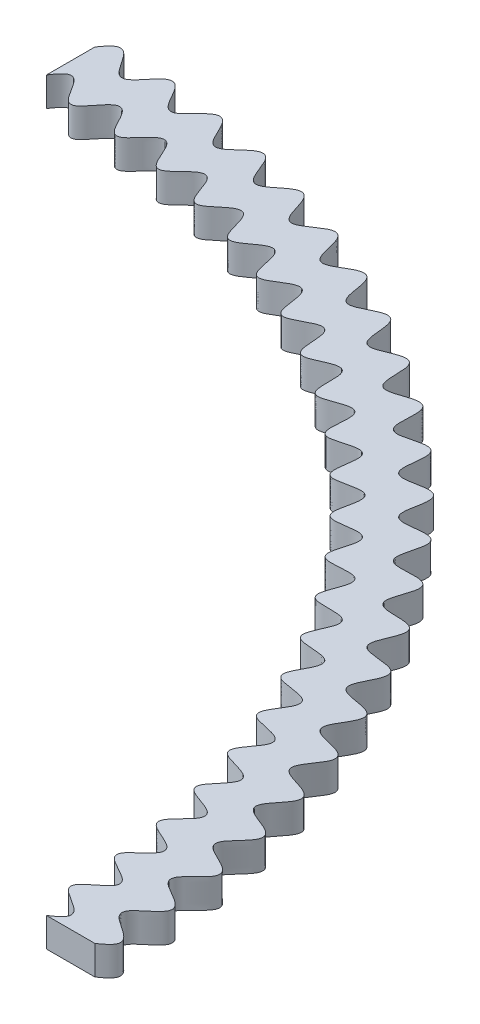
from build123d import *

# Parameters (mm, degrees)
BOSS_EXTRUDE1_DEPTH = 3


with BuildPart() as part:
    # Sketch1 → Boss-Extrude1 (new body)
    with BuildSketch(Plane(origin=(0, 0, 0), x_dir=(1, 0, 0), z_dir=(0, 1, 0))):
        with BuildLine():
            Line((0, 74.999999999), (-3e-09, 79.999999995))
            add(Edge.make_bspline(
                [(80.000000006, 4e-09), (80.041602981, 0.029584342), (80.124672241, 0.088800082), (80.355665628, 0.255037075), (80.580689501, 0.428196266), (80.81426022, 0.628581279), (81.018283424, 0.851310159), (81.156118976, 1.051783354), (81.240847835, 1.272600388), (81.246016618, 1.500136483), (81.179439662, 1.70644663), (81.072093968, 1.882262489), (80.890390621, 2.096864584), (80.621041123, 2.332166671), (80.269616744, 2.584320872), (79.896985228, 2.827334114), (79.578764212, 3.037245118), (79.320425694, 3.220223576), (79.121721975, 3.374962874), (78.935873528, 3.54358104), (78.77263698, 3.733120429), (78.655258735, 3.95143766), (78.623837205, 4.193153253), (78.683771629, 4.421996142), (78.795973835, 4.620716323), (78.984584597, 4.861193351), (79.260256835, 5.129313501), (79.61405676, 5.426162183), (80.034933674, 5.765657885), (80.383334361, 6.069053516), (80.64916782, 6.347378113), (80.823997803, 6.598345889), (80.921414722, 6.805042914), (80.956081188, 7.00900363), (80.930346952, 7.189278292), (80.85921354, 7.366686331), (80.745433267, 7.533712712), (80.581106502, 7.70084266), (80.324453782, 7.904792803), (79.998299993, 8.115192146), (79.608972329, 8.337012133), (79.219952014, 8.552844577), (78.892674075, 8.748998283), (78.64592559, 8.921468474), (78.475904636, 9.061875815), (78.334858695, 9.209053996), (78.228156569, 9.363513244), (78.155173955, 9.554557891), (78.149754157, 9.776640258), (78.224125673, 10.002339681), (78.352006264, 10.217315502), (78.505739272, 10.415655274), (78.67455645, 10.602546042), (78.897195963, 10.827604877), (79.174131922, 11.089585334), (79.498903574, 11.393613444), (79.801202697, 11.702961078), (80.025600848, 11.981460378), (80.167277188, 12.224354966), (80.242468592, 12.41613789), (80.271819825, 12.628249297), (80.229522967, 12.84617985), (80.114958572, 13.043632683), (79.954763592, 13.212416248), (79.720296679, 13.397936958), (79.407072249, 13.587360322), (79.021163384, 13.781984947), (78.56862328, 13.992615128), (78.180049517, 14.181676146), (77.861870547, 14.362378528), (77.620410564, 14.538567295), (77.452426806, 14.699555409), (77.32417893, 14.896997355), (77.274027447, 15.128431228), (77.311347084, 15.361169155), (77.402874819, 15.575335259), (77.557886293, 15.830947416), (77.783602416, 16.118944371), (78.072308857, 16.440385913), (78.413020367, 16.805019864), (78.698748435, 17.129144266), (78.919925667, 17.420606018), (79.070830754, 17.678529716), (79.160125788, 17.893107893), (79.199493523, 18.11766681), (79.166110244, 18.337116848), (79.066113723, 18.526654792), (78.928041208, 18.67989037), (78.758095077, 18.815824302), (78.563403255, 18.937780229), (78.292286184, 19.078874506), (77.94208218, 19.230391033), (77.586564337, 19.368174358), (77.231347046, 19.506941759), (76.940204295, 19.631303183), (76.71304398, 19.740085414), (76.495059028, 19.864369098), (76.293843648, 20.012665137), (76.133111289, 20.19192684), (76.044903019, 20.403806455), (76.03759153, 20.619301189), (76.082831413, 20.816111271), (76.166851605, 21.018822907), (76.283150766, 21.226158295), (76.464160707, 21.496087875), (76.715848987, 21.822467796), (77.019348781, 22.195304011), (77.30833389, 22.569732882), (77.525684967, 22.90276604), (77.662974457, 23.192900926), (77.732396671, 23.428451641), (77.738105048, 23.673858143), (77.65403286, 23.901813951), (77.501220493, 24.084150899), (77.316617595, 24.22536767), (77.056961821, 24.373272726), (76.719688353, 24.515101473), (76.310177077, 24.652935319), (75.83279604, 24.798363036), (75.422047724, 24.932385671), (75.082573559, 25.06894062), (74.82052353, 25.212801385), (74.634175154, 25.352510833), (74.485486432, 25.535407965), (74.413201955, 25.760911321), (74.4255469, 25.996025), (74.490531045, 26.219436675), (74.611547141, 26.492750615), (74.79674702, 26.808332953), (75.038731262, 27.16635148), (75.325327397, 27.575032619), (75.562221965, 27.936536922), (75.738770596, 28.257194582), (75.849064544, 28.535093686), (75.903405684, 28.761362031), (75.903894944, 28.989643398), (75.831559821, 29.199525222), (75.700085204, 29.368543472), (75.539076074, 29.497036653), (75.294933478, 29.636551374), (74.961349304, 29.765539744), (74.544876825, 29.882293142), (74.111602173, 29.983203304), (73.74077851, 30.071617178), (73.435437364, 30.155203688), (73.195792998, 30.232650396), (72.963481772, 30.327535729), (72.745263303, 30.449814307), (72.560294942, 30.614819673), (72.448096761, 30.831211236), (72.426147819, 31.06675199), (72.4636171, 31.291863293), (72.558605253, 31.582346461), (72.725949928, 31.928582446), (72.956884879, 32.328535664), (73.236265441, 32.791505652), (73.459887578, 33.19576434), (73.614496699, 33.548224307), (73.692947109, 33.843852251), (73.713794523, 34.071402468), (73.676611673, 34.274919478), (73.590771834, 34.435520621), (73.46325117, 34.577900586), (73.2992063, 34.695938898), (73.087627842, 34.796786613), (72.776698118, 34.900656658), (72.398252997, 34.986816202), (71.956537759, 35.062100903), (71.517159196, 35.131864274), (71.142530013, 35.204252817), (70.851674004, 35.28192883), (70.643884429, 35.355717981), (70.461006697, 35.44577968), (70.307911322, 35.554429618), (70.17398898, 35.708991339), (70.092939393, 35.915826821), (70.085632009, 36.153351459), (70.132274396, 36.399100391), (70.208899972, 36.638058596), (70.303615821, 36.871417347), (70.435853873, 37.159050671), (70.606485957, 37.499949451), (70.807687744, 37.896720868), (70.985952877, 38.290804947), (71.101565793, 38.629257372), (71.151623163, 38.905959786), (71.156686347, 39.11189376), (71.11172111, 39.321251997), (70.997438426, 39.511573351), (70.822250264, 39.65793499), (70.613988844, 39.761749751), (70.330210196, 39.855889786), (69.971088905, 39.926760459), (69.541887649, 39.977659178), (69.044599288, 40.020808973), (68.614796714, 40.065568163), (68.254002429, 40.12654924), (67.966844158, 40.209528347), (67.753929882, 40.303353861), (67.565887176, 40.445025244), (67.43960515, 40.645349129), (67.395073087, 40.876815308), (67.407831868, 41.109369949), (67.466070639, 41.402583834), (67.579673267, 41.750411961), (67.7410299, 42.151211515), (67.936480421, 42.610385741), (68.094122344, 43.012687467), (68.202270427, 43.362219694), (68.255872094, 43.656199094), (68.266354227, 43.888385509), (68.224901917, 44.122650504), (68.104318198, 44.333580705), (67.912656637, 44.486952094), (67.687590581, 44.585180674), (67.377086382, 44.666505933), (66.982257601, 44.714074936), (66.509672398, 44.733377737), (66.02897738, 44.740537906), (65.617173748, 44.757526467), (65.294044746, 44.792372197), (65.060460964, 44.83655449), (64.851167703, 44.902491816), (64.671322797, 44.994343137), (64.510943988, 45.138461407), (64.40533397, 45.342226454), (64.371328307, 45.580581786), (64.387065703, 45.830044566), (64.431976904, 46.076918739), (64.494660717, 46.320857506), (64.586537292, 46.623823775), (64.708564568, 46.985133974), (64.831538882, 47.346041856), (64.940577283, 47.711706633), (65.00676349, 48.010088012), (65.038485321, 48.23762236), (65.043593155, 48.455185295), (65.014959194, 48.659452909), (64.93404123, 48.85788733), (64.787391105, 49.024520171), (64.590063902, 49.138706426), (64.368289741, 49.208230655), (64.073708805, 49.258420808), (63.708266165, 49.276337222), (63.276310007, 49.265799973), (62.777979058, 49.239182), (62.346163628, 49.224638674), (61.980457633, 49.236850967), (61.685007906, 49.282409616), (61.462114258, 49.349958622), (61.259838062, 49.470971176), (61.114786182, 49.658152267), (61.045973022, 49.883309077), (61.03062685, 50.115473266), (61.050865909, 50.413694301), (61.116961353, 50.773586784), (61.221902611, 51.192777637), (61.351437703, 51.674833939), (61.450404027, 52.095559579), (61.506634094, 52.457262404), (61.515229412, 52.756124894), (61.488905048, 52.987333352), (61.411287976, 53.202015005), (61.271531383, 53.374499337), (61.09017801, 53.488357572), (60.894931662, 53.5540333), (60.617795821, 53.601632568), (60.260212613, 53.608749481), (59.828924484, 53.576019811), (59.387266184, 53.522655686), (59.008566597, 53.478908389), (58.693051506, 53.453021193), (58.441371129, 53.443834092), (58.19061729, 53.453542021), (57.943737267, 53.493811185), (57.713488707, 53.585602609), (57.53404662, 53.750570115), (57.432861723, 53.964399083), (57.391078572, 54.188749622), (57.380987623, 54.494202798), (57.419819195, 54.876792293), (57.500037765, 55.33161223), (57.604219791, 55.862211267), (57.676098977, 56.3185803), (57.700822787, 56.702652388), (57.67345467, 57.007304085), (57.615149415, 57.228200704), (57.493634222, 57.436206163), (57.293851916, 57.590987618), (57.045157933, 57.669958124), (56.778794713, 57.695806221), (56.450951199, 57.686944217), (56.065936691, 57.638539131), (55.625064092, 57.55816628), (55.188350986, 57.473471059), (54.811542784, 57.413351268), (54.511665946, 57.386868814), (54.291168978, 57.385138595), (54.08851738, 57.407221193), (53.907494345, 57.45695706), (53.728785281, 57.556393425), (53.581881675, 57.723034604), (53.493776774, 57.943735486), (53.453555194, 58.190616577), (53.443831163, 58.441371331), (53.453021554, 58.693051555), (53.478908285, 59.008566545), (53.522655746, 59.387266222), (53.576019763, 59.82892446), (53.6087495, 60.260212627), (53.601632557, 60.617795819), (53.554033299, 60.894931664), (53.488357569, 61.090178011), (53.374499333, 61.271531384), (53.202015001, 61.411287977), (52.987333349, 61.488905048), (52.75612489, 61.515229412), (52.457262401, 61.506634095), (52.095559575, 61.450404028), (51.674833936, 61.351437704), (51.192777634, 61.221902611), (50.773586781, 61.116961353), (50.413694298, 61.050865909), (50.115473263, 61.03062685), (49.883309074, 61.045973022), (49.658152264, 61.114786182), (49.470971172, 61.259838062), (49.349958625, 61.462114259), (49.282409586, 61.685007899), (49.236851074, 61.980457657), (49.224638399, 62.346163568), (49.239182516, 62.77797917), (49.265799094, 63.276309817), (49.276338751, 63.708266493), (49.258417644, 64.07370817), (49.208239859, 64.368291294), (49.138677411, 64.590060255), (49.019601634, 64.796019817), (48.834147625, 64.95298731), (48.601588566, 65.031557158), (48.356499502, 65.046884705), (48.03690612, 65.017106759), (47.649618871, 64.926767604), (47.198932097, 64.783272645), (46.744777613, 64.625593625), (46.351998349, 64.500712512), (46.036438468, 64.42294016), (45.801830278, 64.384567576), (45.582607051, 64.374945883), (45.382193119, 64.399747312), (45.182194984, 64.480321403), (45.013262278, 64.635677161), (44.899785083, 64.848027285), (44.829252102, 65.087828125), (44.787018886, 65.3351745), (44.76249043, 65.585841086), (44.745205603, 65.901959892), (44.736298369, 66.283216207), (44.728418659, 66.664418372), (44.70581652, 67.045324195), (44.665958768, 67.34834799), (44.617946208, 67.573009843), (44.548335096, 67.779199111), (44.451564335, 67.961354489), (44.307657753, 68.120146277), (44.112859924, 68.226572631), (43.888379008, 68.266382734), (43.656200779, 68.255862908), (43.362219204, 68.202273611), (43.012687677, 68.094120788), (42.610385615, 67.936481306), (42.151211582, 67.74102937), (41.750411919, 67.579673539), (41.402583844, 67.466070524), (41.10936994, 67.407831893), (40.876815303, 67.395073078), (40.645349123, 67.439605148), (40.445025238, 67.565887173), (40.303353855, 67.753929879), (40.209528342, 67.966844155), (40.126549235, 68.254002426), (40.065568157, 68.61479671), (40.020808968, 69.044599285), (39.977659172, 69.541887646), (39.926760453, 69.971088901), (39.85588978, 70.330210193), (39.761749745, 70.613988841), (39.657934984, 70.82225026), (39.511573345, 70.997438423), (39.32125199, 71.111721107), (39.111893753, 71.156686344), (38.905959779, 71.151623157), (38.629257366, 71.101565798), (38.290804937, 70.985952849), (37.896720871, 70.807687791), (37.49994943, 70.606485882), (37.159050681, 70.435853983), (36.87141742, 70.303615459), (36.638057401, 70.208902649), (36.399105561, 70.132262255), (36.15334136, 70.08566495), (35.905583972, 70.093171028), (35.680541356, 70.186816967), (35.512324841, 70.353143199), (35.396329119, 70.549673064), (35.28237559, 70.833253853), (35.188012018, 71.206051558), (35.107835236, 71.660878864), (35.024258758, 72.195111214), (34.935715696, 72.648541957), (34.827588088, 73.017907704), (34.697673453, 73.294826208), (34.567333342, 73.48245956), (34.382004355, 73.636360111), (34.14133202, 73.713477529), (33.880626616, 73.702627179), (33.621486494, 73.635814859), (33.316445347, 73.515358214), (32.971205569, 73.338189593), (32.584409976, 73.111876509), (32.203001364, 72.882924356), (31.869479657, 72.697554236), (31.596745138, 72.570104951), (31.390137534, 72.493064673), (31.192154629, 72.444504597), (31.005037948, 72.429327505), (30.803097124, 72.461645015), (30.608058252, 72.567992506), (30.449782583, 72.745249842), (30.327547996, 72.963486107), (30.232650717, 73.195787645), (30.155191566, 73.435455453), (30.0716526, 73.740727259), (29.983124108, 74.11171639), (29.882440528, 74.544664357), (29.751508781, 75.010917504), (29.598303138, 75.389689454), (29.409589025, 75.668067133), (29.199483957, 75.831619261), (28.989655263, 75.90387783), (28.761359055, 75.903409954), (28.535094327, 75.849063603), (28.257194312, 75.738770967), (27.936537073, 75.562221729), (27.575032511, 75.325327536), (27.166351534, 75.038731165), (26.808332912, 74.796747061), (26.492750622, 74.611547114), (26.219436665, 74.490531043), (25.996024993, 74.425546892), (25.760911313, 74.413201947), (25.535407957, 74.485486424), (25.352510826, 74.634175146), (25.212801377, 74.820523523), (25.068940612, 75.082573551), (24.932385664, 75.422047717), (24.798363028, 75.832796032), (24.652935311, 76.310177069), (24.515101465, 76.719688345), (24.373272718, 77.056961813), (24.225367661, 77.316617587), (24.084150891, 77.501220485), (23.901813943, 77.654032852), (23.673858135, 77.73810504), (23.428451632, 77.732396663), (23.192900917, 77.662974449), (22.902766032, 77.525684959), (22.569732873, 77.308333882), (22.195304003, 77.019348773), (21.822467788, 76.715848979), (21.496087867, 76.464160698), (21.226158287, 76.283150758), (21.018822899, 76.166851596), (20.816111263, 76.082831404), (20.619301181, 76.037591521), (20.403806447, 76.04490301), (20.191926832, 76.13311128), (20.012665129, 76.293843639), (19.86436909, 76.495059018), (19.740085406, 76.71304397), (19.631303175, 76.940204286), (19.506941751, 77.231347037), (19.368174349, 77.586564328), (19.230391025, 77.942082171), (19.078874498, 78.292286175), (18.93778022, 78.563403245), (18.815824293, 78.758095068), (18.679890362, 78.928041199), (18.526654783, 79.066113714), (18.33711684, 79.166110235), (18.117666801, 79.199493513), (17.893107884, 79.160125778), (17.678529707, 79.070830744), (17.420606009, 78.919925657), (17.129144257, 78.698748425), (16.805019856, 78.413020357), (16.440385904, 78.072308847), (16.118944363, 77.783602405), (15.830947408, 77.557886282), (15.57533525, 77.402874808), (15.361169147, 77.311347074), (15.12843122, 77.274027436), (14.896997347, 77.324178919), (14.699555401, 77.452426796), (14.538567287, 77.620410554), (14.362378519, 77.861870536), (14.181676138, 78.180049506), (13.992615119, 78.568623269), (13.781984938, 79.021163373), (13.587360313, 79.407072238), (13.397936949, 79.720296668), (13.212416239, 79.954763581), (13.043632673, 80.114958561), (12.846179841, 80.229522956), (12.628249288, 80.271819814), (12.416137881, 80.242468581), (12.224354957, 80.167277174), (11.981460367, 80.025600844), (11.702961074, 79.801202661), (11.393613426, 79.498903613), (11.089585337, 79.174131839), (10.827604844, 78.897196063), (10.602546231, 78.674556129), (10.41565323, 78.505741373), (10.217324509, 78.351996617), (10.00231892, 78.224153167), (9.7669359, 78.146468555), (9.523436217, 78.157497846), (9.308477478, 78.256259942), (9.132259981, 78.401264732), (8.928188348, 78.628769106), (8.712011274, 78.946810112), (8.481109637, 79.346785908), (8.219855224, 79.820215253), (7.981569495, 80.216017287), (7.753632286, 80.526125698), (7.536840694, 80.74191062), (7.350186881, 80.87364911), (7.123396806, 80.954882879), (6.870865127, 80.945032428), (6.629587666, 80.84567626), (6.408941436, 80.694245409), (6.211128048, 80.519009435), (6.029457645, 80.332101126), (5.816457306, 80.091906613), (5.614074202, 79.846852311), (5.413538423, 79.600329494), (5.208468818, 79.357528599), (5.038559079, 79.168310469), (4.870784766, 79.000324821), (4.702993212, 78.857255692), (4.533557768, 78.743911446), (4.362916359, 78.665652157), (4.162100828, 78.62695283), (3.942451288, 78.660179501), (3.733095196, 78.772613492), (3.543591661, 78.935881702), (3.374959822, 79.121717773), (3.220226495, 79.32043577), (3.037237303, 79.578735647), (2.827352027, 79.897050868), (2.619008747, 80.216279992), (2.399067846, 80.527958214), (2.206288533, 80.765002441), (2.048256055, 80.931612224), (1.882258289, 81.072078598), (1.706447197, 81.17944176), (1.500136491, 81.24601667), (1.272600365, 81.240847772), (1.051783334, 81.156118924), (0.851310164, 81.018283452), (0.628581245, 80.814260153), (0.428196309, 80.580689577), (0.255036962, 80.355665439), (0.088800199, 80.124672438), (0.029584333, 80.041602966), (-3e-09, 79.999999995)],
                knots=[0.077847526, 0.077847526, 0.077847526, 0.077847526, 0.077847526, 0.079019089, 0.080190652, 0.082533779, 0.083705342, 0.084876905, 0.086048468, 0.087220031, 0.088210559, 0.089201086, 0.090191614, 0.091182141, 0.093644505, 0.096106868, 0.098569231, 0.099800413, 0.101031595, 0.102239172, 0.10344675, 0.104654328, 0.105861906, 0.106959082, 0.108056259, 0.109153436, 0.110250612, 0.112868894, 0.115487176, 0.118105457, 0.120723739, 0.12182072, 0.122917702, 0.124014684, 0.125111666, 0.125758009, 0.126404352, 0.127697039, 0.128989725, 0.130282411, 0.132745478, 0.135208544, 0.13767161, 0.138903144, 0.140134677, 0.141036522, 0.141938367, 0.142840212, 0.143742057, 0.144949635, 0.146157213, 0.147364791, 0.148572368, 0.14980355, 0.151034732, 0.153497095, 0.155959458, 0.158421822, 0.159412349, 0.160402877, 0.161393404, 0.162383932, 0.163504677, 0.164625422, 0.165746167, 0.166866913, 0.169284472, 0.171702032, 0.174119591, 0.176537151, 0.177658304, 0.178779457, 0.17990061, 0.181021763, 0.182142924, 0.183264084, 0.184385245, 0.185506405, 0.187923426, 0.190340446, 0.192757467, 0.195174487, 0.196294788, 0.197415089, 0.198535391, 0.199655692, 0.200646634, 0.201637576, 0.202628519, 0.203619461, 0.204850906, 0.206082351, 0.208545241, 0.211008132, 0.212239577, 0.213471022, 0.214678537, 0.215886051, 0.217093566, 0.21830108, 0.219270311, 0.220239542, 0.221208773, 0.222178004, 0.223508612, 0.22483922, 0.227500436, 0.230161653, 0.232822869, 0.234003972, 0.235185075, 0.236366178, 0.23754728, 0.238667582, 0.239787883, 0.240908184, 0.242028485, 0.244445506, 0.246862526, 0.249279546, 0.251696567, 0.252817727, 0.253938888, 0.255060048, 0.256181209, 0.257302362, 0.258423515, 0.259544668, 0.260665822, 0.263083381, 0.265500941, 0.2679185, 0.27033606, 0.271456805, 0.27257755, 0.273698295, 0.274819041, 0.275809568, 0.276800096, 0.277790623, 0.278781151, 0.281243514, 0.283705877, 0.28616824, 0.287399422, 0.288630604, 0.289838182, 0.291045759, 0.292253337, 0.293460915, 0.294558091, 0.295655268, 0.296752445, 0.297849622, 0.300467903, 0.303086185, 0.305704466, 0.308322748, 0.30941973, 0.310516712, 0.311613693, 0.312710675, 0.313357018, 0.314003362, 0.315296048, 0.316588734, 0.317881421, 0.320344487, 0.322807553, 0.32527062, 0.326502153, 0.327733686, 0.328635531, 0.329537376, 0.330439222, 0.331341067, 0.332548644, 0.333756222, 0.3349638, 0.336171378, 0.337402559, 0.338633741, 0.341096104, 0.343558468, 0.346020831, 0.347011358, 0.348001886, 0.348992413, 0.349982941, 0.351103686, 0.352224431, 0.353345177, 0.354465922, 0.356883481, 0.359301041, 0.3617186, 0.36413616, 0.365257313, 0.366378466, 0.367499619, 0.368620773, 0.369741933, 0.370863094, 0.371984254, 0.373105415, 0.375522435, 0.377939455, 0.380356476, 0.382773496, 0.383893797, 0.385014099, 0.3861344, 0.387254701, 0.388435804, 0.389616907, 0.39079801, 0.391979112, 0.394640329, 0.397301545, 0.399962762, 0.40129337, 0.402623978, 0.403593209, 0.40456244, 0.40553167, 0.406500901, 0.407708416, 0.40891593, 0.410123445, 0.41133096, 0.412562405, 0.41379385, 0.41625674, 0.41871963, 0.419951075, 0.42118252, 0.422173463, 0.423164405, 0.424155347, 0.42514629, 0.426266591, 0.427386892, 0.428507193, 0.429627494, 0.432044515, 0.434461535, 0.436878556, 0.439295576, 0.440416737, 0.441537897, 0.442659058, 0.443780218, 0.444901371, 0.446022525, 0.447143678, 0.448264831, 0.45068239, 0.45309995, 0.455517509, 0.457935069, 0.459055814, 0.460176559, 0.461297305, 0.46241805, 0.463408577, 0.464399105, 0.465389632, 0.46638016, 0.468842523, 0.471304886, 0.47376725, 0.474998431, 0.476229613, 0.477437191, 0.478644769, 0.479852346, 0.481059924, 0.482157101, 0.483254277, 0.484351454, 0.485448631, 0.488066912, 0.490685194, 0.493303476, 0.495921757, 0.497018739, 0.498115721, 0.499212703, 0.500309685, 0.501602371, 0.502895057, 0.504187743, 0.50548043, 0.507943496, 0.510406563, 0.512869629, 0.514101162, 0.515332695, 0.51623454, 0.517136386, 0.518038231, 0.518940076, 0.520147654, 0.521355231, 0.522562809, 0.523770387, 0.525001569, 0.52623275, 0.528695114, 0.531157477, 0.53361984, 0.534610368, 0.535600895, 0.536591423, 0.53758195, 0.538702695, 0.539823441, 0.540944186, 0.542064931, 0.544482491, 0.54690005, 0.54931761, 0.551735169, 0.552856322, 0.553977475, 0.555098629, 0.556219782, 0.557340942, 0.558462103, 0.559583263, 0.560704424, 0.563121444, 0.565538465, 0.567955485, 0.570372506, 0.571492807, 0.572613108, 0.573733409, 0.57485371, 0.576034813, 0.577215916, 0.578397019, 0.579578122, 0.582239338, 0.584900554, 0.587561771, 0.588892379, 0.590222987, 0.591192218, 0.592161449, 0.59313068, 0.59409991, 0.595307425, 0.59651494, 0.597722454, 0.598929969, 0.600161414, 0.601392859, 0.603855749, 0.60631864, 0.607550085, 0.60878153, 0.609772472, 0.610763414, 0.611754357, 0.612745299, 0.6138656, 0.614985901, 0.616106203, 0.617226504, 0.619643524, 0.622060545, 0.624477565, 0.626894585, 0.628015746, 0.629136906, 0.630258067, 0.631379227, 0.632500381, 0.633621534, 0.634742687, 0.63586384, 0.6382814, 0.640698959, 0.643116519, 0.645534078, 0.646654823, 0.647775569, 0.648896314, 0.650017059, 0.651007587, 0.651998114, 0.652988642, 0.653979169, 0.656441532, 0.658903896, 0.661366259, 0.662597441, 0.663828622, 0.6650362, 0.666243778, 0.667451356, 0.668658933, 0.66975611, 0.670853287, 0.671950463, 0.67304764, 0.675665922, 0.678284203, 0.680902485, 0.683520766, 0.684617748, 0.68571473, 0.686811712, 0.687908694, 0.68920138, 0.690494066, 0.691786753, 0.693079439, 0.695542505, 0.698005572, 0.700468638, 0.701700171, 0.702931705, 0.70383355, 0.704735395, 0.70563724, 0.706539085, 0.707746663, 0.708954241, 0.710161818, 0.711369396, 0.712600578, 0.71383176, 0.716294123, 0.718756486, 0.721218849, 0.723199904, 0.724190432, 0.725180959, 0.726301705, 0.72742245, 0.728543195, 0.72966394, 0.7320815, 0.734499059, 0.736916619, 0.739334178, 0.740455332, 0.741576485, 0.742697638, 0.743818791, 0.744939952, 0.746061112, 0.747182273, 0.748303433, 0.750720454, 0.753137474, 0.755554494, 0.757971515, 0.759091816, 0.760212117, 0.761332418, 0.76245272, 0.763633822, 0.764814925, 0.765996028, 0.767177131, 0.769838347, 0.772499564, 0.77516078, 0.776491388, 0.777821996, 0.778791227, 0.779760458, 0.780729689, 0.78169892, 0.782906434, 0.784113949, 0.785321463, 0.786528978, 0.787760423, 0.788991868, 0.791454759, 0.793917649, 0.795149094, 0.796380539, 0.797371481, 0.798362424, 0.799353366, 0.800344308, 0.801464609, 0.802584911, 0.803705212, 0.804825513, 0.807242533, 0.809659554, 0.812076574, 0.814493595, 0.815614755, 0.816735916, 0.817857076, 0.818978237, 0.82009939, 0.821220543, 0.822341696, 0.823462849, 0.825880409, 0.828297968, 0.830715528, 0.833133087, 0.834253833, 0.835374578, 0.836495323, 0.837616068, 0.838606596, 0.839597123, 0.840587651, 0.841578178, 0.844040542, 0.846502905, 0.848965268, 0.85019645, 0.851427632, 0.852635209, 0.853842787, 0.855050365, 0.856257943, 0.857355119, 0.858452296, 0.859549473, 0.860646649, 0.863264931, 0.865883212, 0.868501494, 0.871119776, 0.872216757, 0.873313739, 0.874410721, 0.875507703, 0.876800389, 0.878093076, 0.879385762, 0.880678448, 0.881909981, 0.883141515, 0.885604581, 0.886836114, 0.888067647, 0.889299181, 0.890530714, 0.891432559, 0.892334404, 0.893236249, 0.894138094, 0.895345672, 0.89655325, 0.897760828, 0.898968405, 0.900199587, 0.901430769, 0.903893132, 0.906355495, 0.907586677, 0.908817859, 0.909808386, 0.910798914, 0.911789441, 0.912779969, 0.913951532, 0.915123095, 0.916294658, 0.917466221, 0.919809348, 0.920980911, 0.922152474, 0.922152474, 0.922152474, 0.922152474, 0.922152474], degree=4))
            Line((80.000000006, 4e-09), (75.000000004, 2e-09))
            add(Edge.make_bspline(
                [(75.000000004, 2e-09), (75.041112304, 0.027408202), (75.125245618, 0.083633527), (75.342933359, 0.230577445), (75.579476754, 0.400277402), (75.803954397, 0.581129456), (76.011836213, 0.790840241), (76.152032621, 0.978806112), (76.24241055, 1.192222573), (76.247194642, 1.417755832), (76.171590232, 1.621283716), (76.05304035, 1.792429831), (75.90172017, 1.952322238), (75.724822764, 2.103749447), (75.475174444, 2.28826604), (75.149562183, 2.499244923), (74.762604266, 2.733844062), (74.390525758, 2.967660929), (74.09699875, 3.180516489), (73.88802182, 3.373771758), (73.754852084, 3.533069482), (73.660678307, 3.715826878), (73.634383636, 3.916077066), (73.679915907, 4.107591167), (73.770283936, 4.275986249), (73.894495185, 4.43915278), (74.045788678, 4.598579932), (74.265577575, 4.798748114), (74.557807483, 5.033508596), (74.855966797, 5.260237374), (75.151185231, 5.491052126), (75.387608176, 5.691635422), (75.566675764, 5.85948229), (75.730748464, 6.039389737), (75.870288221, 6.236516846), (75.96158188, 6.450809963), (75.973056412, 6.672596727), (75.906427471, 6.870219292), (75.7967839, 7.031782359), (75.649110794, 7.183951167), (75.469925437, 7.327656179), (75.20902009, 7.502392042), (74.862370617, 7.698495985), (74.449730011, 7.911567615), (74.04576531, 8.125033199), (73.717888837, 8.324746294), (73.474215021, 8.516344267), (73.310194841, 8.687844962), (73.209978852, 8.874644981), (73.187392108, 9.054219475), (73.215253495, 9.232640917), (73.284935962, 9.401931795), (73.400574208, 9.57936679), (73.556680051, 9.766323157), (73.727550503, 9.942822406), (73.952817036, 10.156161775), (74.233076975, 10.405234119), (74.514063245, 10.653334113), (74.785870436, 10.911917321), (74.986481147, 11.131582379), (75.121662579, 11.305079053), (75.228863456, 11.479909986), (75.302210189, 11.656119553), (75.333173341, 11.858984025), (75.28726906, 12.074305869), (75.158471774, 12.268341058), (74.980105223, 12.432099832), (74.728460021, 12.606792635), (74.401490902, 12.782190323), (74.005435938, 12.962261524), (73.545966651, 13.159101967), (73.162792446, 13.336282194), (72.861677728, 13.505559027), (72.648318942, 13.66688771), (72.513794706, 13.801989015), (72.412981349, 13.965633703), (72.371963727, 14.153980983), (72.397238744, 14.34466996), (72.46750777, 14.522166659), (72.570326866, 14.699473574), (72.699548751, 14.877274657), (72.890625301, 15.105072216), (73.14803079, 15.377641415), (73.411870086, 15.643649027), (73.671714612, 15.913786405), (73.877113402, 16.146162467), (74.029977124, 16.338298379), (74.165497142, 16.540721786), (74.273001526, 16.757307213), (74.326194497, 16.981151405), (74.299446757, 17.194622935), (74.207844951, 17.370179189), (74.086475226, 17.505519057), (73.932240136, 17.628565525), (73.75045752, 17.740323678), (73.490079216, 17.871024766), (73.14804152, 18.010331831), (72.742635445, 18.155041363), (72.333783965, 18.299564959), (71.985228708, 18.438749069), (71.701248824, 18.580522321), (71.484211274, 18.720941327), (71.306471595, 18.895439189), (71.21165515, 19.112480644), (71.21369044, 19.332867896), (71.271629166, 19.528589431), (71.368375751, 19.727885072), (71.496696775, 19.930960942), (71.691975729, 20.195184943), (71.958922369, 20.515350746), (72.231412428, 20.830517711), (72.494647941, 21.153852316), (72.684260198, 21.422165126), (72.806947203, 21.628655645), (72.897284568, 21.830787559), (72.949258963, 22.0276948), (72.948390205, 22.242980958), (72.862768576, 22.453004375), (72.700947371, 22.624229263), (72.499570935, 22.758070637), (72.280988779, 22.865605496), (72.052538323, 22.955570004), (71.758469576, 23.05411398), (71.398368957, 23.158137602), (71.0368736, 23.25658727), (70.677669318, 23.363936395), (70.398293387, 23.465676586), (70.197483413, 23.5550459), (70.01978601, 23.657188643), (69.870182886, 23.775770783), (69.752949588, 23.928274773), (69.694298323, 24.111897098), (69.699782917, 24.304024231), (69.748732198, 24.488287845), (69.852850216, 24.734680109), (70.028959095, 25.031841334), (70.272263331, 25.37685837), (70.534233793, 25.727055661), (70.753379005, 26.031183812), (70.92352551, 26.290634738), (71.046861754, 26.503046559), (71.150721007, 26.723540479), (71.223301144, 26.954542049), (71.238153462, 27.191377729), (71.165221923, 27.4089655), (71.023362719, 27.575720345), (70.853435391, 27.696006314), (70.656552661, 27.794499864), (70.438532507, 27.876292608), (70.140831355, 27.964296644), (69.762696969, 28.051186077), (69.318837774, 28.139289688), (68.889228309, 28.231747371), (68.540602237, 28.331373999), (68.27813097, 28.441500237), (68.09850932, 28.545644399), (67.947508205, 28.685170848), (67.8543097, 28.864351164), (67.831594358, 29.059888506), (67.858918018, 29.249035808), (67.919832172, 29.444844943), (68.007474253, 29.646402882), (68.145546708, 29.909671676), (68.339860183, 30.230222884), (68.54249248, 30.545254735), (68.74096377, 30.863120305), (68.894525139, 31.132468358), (69.00538662, 31.351437543), (69.098032555, 31.576611412), (69.161735593, 31.809575709), (69.174231007, 32.04216964), (69.109158, 32.254505546), (68.978956378, 32.417421573), (68.8206673, 32.531740885), (68.629855174, 32.624225614), (68.412326008, 32.697979152), (68.107391994, 32.772942269), (67.714576543, 32.838658594), (67.253946421, 32.897749033), (66.801334243, 32.960177002), (66.424925239, 33.035705566), (66.130416386, 33.132407414), (65.917631141, 33.237467146), (65.759569546, 33.378725858), (65.676926856, 33.539745565), (65.642084268, 33.716936032), (65.649663478, 33.899850229), (65.697641542, 34.106135193), (65.780390207, 34.335208054), (65.880589612, 34.559504233), (66.019304549, 34.837023356), (66.197474987, 35.166929344), (66.376660516, 35.496170042), (66.543635062, 35.832122308), (66.657017592, 36.107152847), (66.724707228, 36.316421164), (66.765647401, 36.517373361), (66.774303563, 36.708042251), (66.734015673, 36.90926252), (66.617235351, 37.095898679), (66.429841549, 37.234180848), (66.206223018, 37.327058806), (65.910005421, 37.405148616), (65.54276541, 37.458138504), (65.109007505, 37.491891307), (64.60992421, 37.519713068), (64.18925903, 37.555154723), (63.848407665, 37.611235614), (63.592738329, 37.689861985), (63.420119529, 37.770805686), (63.269416182, 37.890101193), (63.166453661, 38.053060889), (63.124984937, 38.240894479), (63.130308776, 38.431720239), (63.166284586, 38.633500441), (63.226901883, 38.844775294), (63.328543762, 39.124187007), (63.477201624, 39.468356139), (63.634149539, 39.808559875), (63.785931036, 40.151278048), (63.899465718, 40.439890625), (63.97739403, 40.672721898), (64.03551945, 40.909287619), (64.062433287, 41.149582496), (64.035284079, 41.383605967), (63.929433329, 41.58419639), (63.765072991, 41.723245172), (63.580824796, 41.81000001), (63.367915028, 41.870725464), (63.130872427, 41.909471313), (62.80345248, 41.936688047), (62.386559277, 41.942873423), (61.96997414, 41.936719348), (61.553122914, 41.938024968), (61.225192693, 41.958272525), (60.987144388, 41.990507571), (60.772287564, 42.044500155), (60.585113874, 42.125923894), (60.414979185, 42.266026966), (60.30966262, 42.478172135), (60.290238366, 42.726493692), (60.322180215, 42.983013698), (60.396114354, 43.291685), (60.51354014, 43.648159639), (60.665633309, 44.05425602), (60.815369377, 44.457832585), (60.928511567, 44.809393517), (60.995756673, 45.09286791), (61.026992574, 45.303958229), (61.031873915, 45.501201908), (61.006212517, 45.681171301), (60.93060913, 45.86418774), (60.784273566, 46.021894552), (60.578607185, 46.125030646), (60.343590635, 46.181895939), (60.101414721, 46.20819684), (59.855971167, 46.214599018), (59.545932978, 46.20662287), (59.1719709, 46.181211375), (58.798604616, 46.150085145), (58.424347437, 46.128105204), (58.127022743, 46.128157524), (57.907756986, 46.14345615), (57.705841168, 46.17866284), (57.524702749, 46.238926322), (57.362380049, 46.342137048), (57.244463281, 46.494625667), (57.183905754, 46.677041957), (57.166882663, 46.866934945), (57.180442105, 47.134077336), (57.244321338, 47.473553644), (57.354893041, 47.880971369), (57.499445678, 48.359471861), (57.616082359, 48.778615102), (57.691891633, 49.14183144), (57.7198236, 49.446893217), (57.70902891, 49.688792033), (57.643178631, 49.912179894), (57.507739232, 50.085750827), (57.332433301, 50.192430445), (57.150302569, 50.249508914), (56.947466906, 50.279767434), (56.727667841, 50.287733988), (56.430444369, 50.275255135), (56.057644355, 50.233253124), (55.686973231, 50.177480149), (55.316026892, 50.122890284), (55.007795869, 50.087455179), (54.762786332, 50.070025877), (54.519099914, 50.070566498), (54.279131026, 50.099783797), (54.076955351, 50.171870635), (53.934932161, 50.28653274), (53.834139439, 50.434480375), (53.774948777, 50.603748662), (53.752200545, 50.81040236), (53.762075934, 51.120092355), (53.819834524, 51.499702152), (53.915977978, 51.946327195), (54.017993532, 52.399414034), (54.090592349, 52.791003138), (54.124443142, 53.103191819), (54.129536998, 53.33282583), (54.107891342, 53.543762546), (54.054604381, 53.731605137), (53.946044971, 53.909675189), (53.768770767, 54.043446972), (53.545930282, 54.111256935), (53.305227729, 54.131074141), (53.06194673, 54.12102944), (52.818266143, 54.091745596), (52.512640684, 54.03956757), (52.146063574, 53.961781991), (51.780726142, 53.879117156), (51.413047413, 53.806157186), (51.118432112, 53.766454752), (50.899054251, 53.753035012), (50.694219948, 53.76276508), (50.507134455, 53.801781464), (50.331158556, 53.89000461), (50.194659854, 54.038865811), (50.11519114, 54.228480156), (50.078778904, 54.432897688), (50.068117139, 54.652502887), (50.077011593, 54.885075), (50.10649365, 55.194018267), (50.160603337, 55.578093958), (50.229645529, 56.025340496), (50.280902122, 56.461946343), (50.291590712, 56.824735736), (50.259051979, 57.107868261), (50.204119125, 57.308676583), (50.095942152, 57.499015662), (49.91642049, 57.641968237), (49.688787941, 57.709014189), (49.446893557, 57.719818333), (49.204175129, 57.697635944), (48.962389814, 57.654386898), (48.660392165, 57.583238928), (48.299653108, 57.481327742), (47.880976123, 57.354930561), (47.47355121, 57.244302141), (47.134078216, 57.180449052), (46.866934764, 57.166881236), (46.677041966, 57.183905825), (46.494625675, 57.244463343), (46.342137046, 57.362380038), (46.238926321, 57.524702739), (46.178662841, 57.705841171), (46.14345615, 57.907756985), (46.128157521, 58.127022742), (46.12810521, 58.424347437), (46.15008513, 58.798604613), (46.181211397, 59.171970902), (46.206622832, 59.54593297), (46.21459922, 59.855971227), (46.208194894, 60.101414108), (46.181904681, 60.343593235), (46.125009727, 60.578601632), (46.019457075, 60.789226185), (45.851383941, 60.941516437), (45.64937826, 61.015965005), (45.446569688, 61.034471292), (45.225730622, 61.018715124), (44.989731578, 60.974050968), (44.672748799, 60.887642115), (44.278881809, 60.750868593), (43.889524648, 60.602605147), (43.497366078, 60.461260512), (43.182287398, 60.368128251), (42.947570126, 60.31700197), (42.727204203, 60.294253041), (42.523469909, 60.306749156), (42.315677524, 60.380213487), (42.144154405, 60.543544351), (42.040970601, 60.770246799), (41.983251112, 61.022221512), (41.947154674, 61.337564622), (41.935577312, 61.712703194), (41.939604997, 62.146327894), (41.942279561, 62.576778566), (41.928357522, 62.945834686), (41.894593299, 63.235212663), (41.851748304, 63.444255985), (41.788873953, 63.631273932), (41.703206969, 63.791613128), (41.569567715, 63.937734443), (41.378118359, 64.035880661), (41.149580557, 64.062454841), (40.909288163, 64.035510343), (40.672721806, 63.977396066), (40.439890635, 63.899465505), (40.15127804, 63.785931073), (39.808559879, 63.634149514), (39.468356134, 63.477201636), (39.124187008, 63.328543753), (38.844775293, 63.226901883), (38.63350044, 63.166284584), (38.431720238, 63.130308774), (38.240894478, 63.124984935), (38.053060888, 63.166453659), (37.890101191, 63.26941618), (37.770805685, 63.420119527), (37.689861984, 63.592738327), (37.611235613, 63.848407663), (37.555154722, 64.189259028), (37.519713067, 64.609924208), (37.491891306, 65.109007503), (37.458138502, 65.542765408), (37.405148614, 65.910005419), (37.327058805, 66.206223015), (37.234180847, 66.429841547), (37.095898677, 66.617235348), (36.909262518, 66.734015671), (36.70804225, 66.774303561), (36.517373359, 66.765647398), (36.316421159, 66.724707223), (36.107152878, 66.657017628), (35.832122194, 66.543634927), (35.496170306, 66.376660834), (35.166928866, 66.19747439), (34.837024163, 66.019305577), (34.559501264, 65.880586251), (34.335228783, 65.780409868), (34.106053551, 65.697572222), (33.870563653, 65.642953308), (33.655925513, 65.641544624), (33.483250619, 65.700716967), (33.337935371, 65.805269127), (33.224421179, 65.944084887), (33.132365105, 66.130495489), (33.035724719, 66.424886474), (32.960165843, 66.8013576), (32.897756376, 67.253930856), (32.838654814, 67.714584589), (32.772944025, 68.107388238), (32.697978548, 68.412327292), (32.624225749, 68.629854878), (32.53174088, 68.820667303), (32.417421566, 68.978956386), (32.254505545, 69.109157995), (32.042169639, 69.174231003), (31.809575707, 69.161735591), (31.57661141, 69.098032551), (31.351437541, 69.005386618), (31.132468356, 68.894525136), (30.863120303, 68.740963767), (30.545254733, 68.542492477), (30.230222883, 68.33986018), (29.909671674, 68.145546704), (29.646402881, 68.007474252), (29.444844946, 67.919832174), (29.249035783, 67.858917989), (29.059888537, 67.83159439), (28.86435119, 67.854309727), (28.685170838, 67.947508193), (28.545642748, 68.098507493), (28.441511525, 68.278143421), (28.356383342, 68.480858268), (28.285197047, 68.702446649), (28.207236297, 69.002841815), (28.126721149, 69.38226151), (28.038632262, 69.826149602), (27.93746971, 70.253955683), (27.823432419, 70.59852191), (27.696018984, 70.853450552), (27.575718496, 71.023360508), (27.408965594, 71.165222033), (27.191377752, 71.238153488), (26.95454206, 71.223301157), (26.723540457, 71.15072098), (26.503046565, 71.046861761), (26.290634734, 70.923525504), (26.031183811, 70.753379002), (25.727055659, 70.534233789), (25.376858368, 70.272263328), (25.031841332, 70.028959091), (24.734680107, 69.852850213), (24.488287843, 69.748732194), (24.304024229, 69.699782913), (24.111897096, 69.694298319), (23.928274771, 69.752949585), (23.775770781, 69.870182882), (23.657188641, 70.019786006), (23.555045898, 70.197483409), (23.465676584, 70.398293383), (23.363936393, 70.677669314), (23.256587268, 71.036873596), (23.1581376, 71.398368953), (23.054113978, 71.758469572), (22.955570001, 72.052538319), (22.865605494, 72.280988775), (22.758070635, 72.499570931), (22.624229261, 72.700947367), (22.453004373, 72.862768572), (22.242980955, 72.948390201), (22.027694798, 72.949258959), (21.830787557, 72.897284564), (21.628655643, 72.806947199), (21.422165123, 72.684260194), (21.153852314, 72.494647937), (20.830517709, 72.231412424), (20.515350743, 71.958922365), (20.195184941, 71.691975725), (19.930960939, 71.496696771), (19.727885069, 71.368375747), (19.528589429, 71.271629162), (19.332867894, 71.213690436), (19.112480642, 71.211655145), (18.895439187, 71.306471591), (18.720941324, 71.484211269), (18.580522319, 71.70124882), (18.438749067, 71.985228704), (18.299564957, 72.333783961), (18.155041361, 72.742635441), (18.010331829, 73.148041516), (17.871024764, 73.490079211), (17.740323676, 73.750457516), (17.628565523, 73.932240132), (17.505519054, 74.086475222), (17.370179187, 74.207844947), (17.194622933, 74.299446752), (16.981151403, 74.326194492), (16.757307211, 74.273001521), (16.540721783, 74.165497137), (16.338298376, 74.02997712), (16.146162465, 73.877113397), (15.913786402, 73.671714607), (15.643649025, 73.411870082), (15.377641412, 73.148030785), (15.105072214, 72.890625296), (14.877274654, 72.699548746), (14.699473571, 72.570326862), (14.522166657, 72.467507765), (14.344669958, 72.397238739), (14.153980981, 72.371963722), (13.9656337, 72.412981344), (13.801989013, 72.513794701), (13.666887708, 72.648318937), (13.505559024, 72.861677723), (13.336282192, 73.162792441), (13.159101965, 73.545966646), (12.962261521, 74.005435933), (12.78219032, 74.401490897), (12.606792632, 74.728460016), (12.432099829, 74.980105218), (12.268341056, 75.158471769), (12.074305867, 75.287269055), (11.858984023, 75.333173336), (11.656119551, 75.302210184), (11.479909983, 75.22886345), (11.305079049, 75.12166257), (11.131582395, 74.986481189), (10.911917258, 74.785870268), (10.65333425, 74.514063632), (10.405233873, 74.233076248), (10.15616218, 73.952818275), (9.942820764, 73.727546327), (9.766335909, 73.556705613), (9.579313778, 73.400481142), (9.376706427, 73.268613864), (9.175494349, 73.193879566), (8.992994893, 73.190425088), (8.820684282, 73.238971239), (8.666538047, 73.330591245), (8.516277453, 73.47427488), (8.324777548, 73.717858957), (8.125014722, 74.045783439), (7.911579836, 74.449717893), (7.698489679, 74.862376882), (7.502394975, 75.209017159), (7.32765517, 75.469926434), (7.183951393, 75.64911056), (7.031782351, 75.796783899), (6.870219281, 75.906427474), (6.672596725, 75.973056404), (6.450809962, 75.961581873), (6.236516843, 75.870288216), (6.039389734, 75.730748457), (5.859482287, 75.566675758), (5.691635419, 75.38760817), (5.491052124, 75.151185225), (5.260237371, 74.855966791), (5.033508594, 74.557807478), (4.798748111, 74.265577567), (4.59857993, 74.045788673), (4.439152781, 73.894495186), (4.275986234, 73.770283898), (4.107591183, 73.679915945), (3.916077079, 73.634383668), (3.715826872, 73.66067829), (3.533068552, 73.7548498), (3.373778105, 73.88803738), (3.22445122, 74.049411476), (3.081770285, 74.233289274), (2.905769976, 74.488904321), (2.700341235, 74.817904232), (2.465746234, 75.204894777), (2.224365996, 75.572300772), (1.999357801, 75.85708508), (1.792436567, 76.053058971), (1.621282729, 76.171587512), (1.417755872, 76.247194755), (1.192222586, 76.242410584), (0.978806118, 76.152032637), (0.790840227, 76.011836176), (0.581129461, 75.80395441), (0.400277396, 75.579476739), (0.230577444, 75.342933356), (0.083633524, 75.125245612), (0.0274082, 75.041112297), (0, 74.999999999)],
                knots=[0.077452672, 0.077452672, 0.077452672, 0.077452672, 0.077452672, 0.078625649, 0.079798627, 0.082144582, 0.08331756, 0.084490537, 0.085663515, 0.086836493, 0.087872675, 0.088908858, 0.089945041, 0.090981224, 0.092278052, 0.093574881, 0.096168538, 0.098762196, 0.101355853, 0.102391788, 0.103427722, 0.104463657, 0.105499592, 0.106449186, 0.10739878, 0.108348374, 0.109297968, 0.110550679, 0.11180339, 0.114308811, 0.116814233, 0.118066944, 0.119319655, 0.120527329, 0.121735003, 0.122942678, 0.124150352, 0.125119735, 0.126089119, 0.127058503, 0.128027886, 0.129358791, 0.130689696, 0.133351506, 0.136013315, 0.138675125, 0.13985721, 0.141039294, 0.142221379, 0.143403464, 0.144008045, 0.144612626, 0.145821788, 0.147030951, 0.148240113, 0.149493641, 0.150747169, 0.153254225, 0.155761281, 0.157014809, 0.158268337, 0.159217833, 0.16016733, 0.161116827, 0.162066323, 0.163275136, 0.164483949, 0.165692762, 0.166901575, 0.169408126, 0.171914676, 0.174421227, 0.176927777, 0.177877176, 0.178826575, 0.179775974, 0.180725373, 0.181674956, 0.18262454, 0.183574123, 0.184523706, 0.18577669, 0.187029673, 0.189535639, 0.192041606, 0.193294589, 0.194547572, 0.195755776, 0.19696398, 0.198172183, 0.199380387, 0.200283821, 0.201187256, 0.20209069, 0.202994124, 0.204227947, 0.20546177, 0.207929416, 0.210397062, 0.212864708, 0.214160334, 0.215455959, 0.216751585, 0.218047211, 0.219060591, 0.220073972, 0.221087353, 0.222100734, 0.223494094, 0.224887455, 0.227674176, 0.230460897, 0.231854258, 0.233247618, 0.234259895, 0.235272172, 0.236284448, 0.237296725, 0.238504929, 0.239713132, 0.240921336, 0.24212954, 0.243382523, 0.244635506, 0.247141473, 0.249647439, 0.250900422, 0.252153406, 0.253102989, 0.254052573, 0.255002156, 0.255951739, 0.256901138, 0.257850537, 0.258799936, 0.259749335, 0.262255885, 0.264762436, 0.267268986, 0.268522261, 0.269775537, 0.27098435, 0.272193163, 0.273401976, 0.274610789, 0.275646971, 0.276683154, 0.277719337, 0.27875552, 0.280052348, 0.281349177, 0.283942834, 0.286536492, 0.289130149, 0.290166084, 0.291202018, 0.292237953, 0.293273888, 0.294223482, 0.295173076, 0.29612267, 0.297072264, 0.298324975, 0.299577686, 0.302083107, 0.304588529, 0.30584124, 0.307093951, 0.308301625, 0.309509299, 0.310716974, 0.311924648, 0.312894031, 0.313863415, 0.314832799, 0.315802182, 0.317133087, 0.318463992, 0.321125802, 0.323787611, 0.326449421, 0.327631505, 0.32881359, 0.329995675, 0.33117776, 0.331782341, 0.332386922, 0.333596084, 0.334805247, 0.336014409, 0.337267937, 0.338521465, 0.341028521, 0.343535577, 0.344789105, 0.346042633, 0.346992129, 0.347941626, 0.348891123, 0.349840619, 0.351049432, 0.352258245, 0.353467058, 0.354675871, 0.357182422, 0.359688972, 0.362195523, 0.364702073, 0.365651472, 0.366600871, 0.36755027, 0.368499669, 0.369449252, 0.370398835, 0.371348419, 0.372298002, 0.373550986, 0.374803969, 0.377309935, 0.379815902, 0.381068885, 0.382321868, 0.383530072, 0.384738276, 0.385946479, 0.387154683, 0.38816696, 0.389179236, 0.390191513, 0.39120379, 0.39259715, 0.393990511, 0.396777232, 0.399563953, 0.400957314, 0.402350674, 0.403364055, 0.404377436, 0.405390817, 0.406404197, 0.407699823, 0.408995449, 0.410291074, 0.4115867, 0.414054346, 0.416521992, 0.418989638, 0.420223461, 0.421457284, 0.422360718, 0.423264152, 0.424167587, 0.425071021, 0.426279225, 0.427487428, 0.428695632, 0.429903836, 0.431156819, 0.432409802, 0.434915769, 0.437421735, 0.438674718, 0.439927702, 0.440877285, 0.441826869, 0.442776452, 0.443726035, 0.444675434, 0.445624833, 0.446574232, 0.447523631, 0.450030181, 0.452536732, 0.455043282, 0.457549833, 0.458758646, 0.459967459, 0.461176272, 0.462385085, 0.463334581, 0.464284078, 0.465233575, 0.466183071, 0.467436599, 0.468690127, 0.471197183, 0.473704239, 0.474957767, 0.476211295, 0.477420457, 0.47862962, 0.479838782, 0.481047944, 0.481638987, 0.482230029, 0.483412114, 0.484594199, 0.485776283, 0.488438093, 0.491099902, 0.493761712, 0.495092617, 0.496423522, 0.497392905, 0.498362289, 0.499331673, 0.500301056, 0.50150873, 0.502716405, 0.503924079, 0.505131753, 0.506384464, 0.507637175, 0.510142597, 0.512648018, 0.513900729, 0.51515344, 0.516103034, 0.517052628, 0.518002222, 0.518951816, 0.519987751, 0.521023686, 0.52205962, 0.523095555, 0.524392384, 0.525689213, 0.52828287, 0.530876527, 0.533470184, 0.534506367, 0.53554255, 0.536578733, 0.537614915, 0.538823728, 0.540032541, 0.541241354, 0.542450167, 0.543703443, 0.544956718, 0.547463268, 0.549969819, 0.552476369, 0.553425768, 0.554375167, 0.555324566, 0.556273965, 0.557223548, 0.558173131, 0.559122715, 0.560072298, 0.561325282, 0.562578265, 0.565084231, 0.567590198, 0.568843181, 0.570096164, 0.571304368, 0.572512572, 0.573720775, 0.574928979, 0.575941256, 0.576953532, 0.577965809, 0.578978086, 0.580371446, 0.581764807, 0.584551528, 0.587338249, 0.58873161, 0.59012497, 0.591138351, 0.592151732, 0.593165113, 0.594178493, 0.595474119, 0.596769745, 0.59806537, 0.599360996, 0.601828642, 0.604296288, 0.606763934, 0.607997757, 0.60923158, 0.610135014, 0.611038448, 0.611941883, 0.612845317, 0.614053521, 0.615261724, 0.616469928, 0.617678132, 0.618931115, 0.620184098, 0.622690065, 0.625196031, 0.626449014, 0.627701998, 0.628651581, 0.629601165, 0.630550748, 0.631500331, 0.63244973, 0.633399129, 0.634348528, 0.635297927, 0.637804477, 0.640311028, 0.642817578, 0.645324129, 0.646532942, 0.647741755, 0.648950568, 0.650159381, 0.651108877, 0.652058374, 0.653007871, 0.653957367, 0.655210895, 0.656464423, 0.658971479, 0.661478535, 0.662732063, 0.663985591, 0.665194753, 0.666403916, 0.667613078, 0.66882224, 0.669413283, 0.670004325, 0.67118641, 0.672368495, 0.673550579, 0.676212389, 0.678874198, 0.681536008, 0.682866913, 0.684197818, 0.685167201, 0.686136585, 0.687105969, 0.688075352, 0.689283026, 0.690490701, 0.691698375, 0.692906049, 0.69415876, 0.695411471, 0.697916893, 0.700422314, 0.701675025, 0.702927736, 0.70387733, 0.704826924, 0.705776518, 0.706726112, 0.707762047, 0.708797982, 0.709833916, 0.710869851, 0.71216668, 0.713463508, 0.716057166, 0.718650823, 0.72124448, 0.722280663, 0.723316846, 0.724353029, 0.725389211, 0.726598024, 0.727806837, 0.72901565, 0.730224463, 0.731477739, 0.732731014, 0.735237564, 0.737744115, 0.740250665, 0.741200064, 0.742149463, 0.743098862, 0.744048261, 0.744997844, 0.745947427, 0.746897011, 0.747846594, 0.749099578, 0.750352561, 0.752858527, 0.755364494, 0.756617477, 0.75787046, 0.759078664, 0.760286868, 0.761495071, 0.762703275, 0.763715552, 0.764727828, 0.765740105, 0.766752382, 0.768145742, 0.769539103, 0.772325824, 0.775112545, 0.776505906, 0.777899266, 0.778912647, 0.779926028, 0.780939409, 0.781952789, 0.783248415, 0.784544041, 0.785839666, 0.787135292, 0.789602938, 0.792070584, 0.79453823, 0.795772053, 0.797005876, 0.79790931, 0.798812744, 0.799716179, 0.800619613, 0.801827817, 0.80303602, 0.804244224, 0.805452428, 0.806705411, 0.807958394, 0.810464361, 0.812970327, 0.81422331, 0.815476294, 0.816425877, 0.81737546, 0.818325044, 0.819274627, 0.820224026, 0.821173425, 0.822122824, 0.823072223, 0.825578773, 0.828085324, 0.830591874, 0.833098425, 0.834307238, 0.835516051, 0.836724864, 0.837933677, 0.838883173, 0.83983267, 0.840782167, 0.841731663, 0.842985191, 0.844238719, 0.846745775, 0.849252831, 0.850506359, 0.851759887, 0.852969049, 0.854178212, 0.855387374, 0.856596536, 0.857187579, 0.857778621, 0.858960706, 0.86014279, 0.861324875, 0.863986685, 0.866648494, 0.869310304, 0.870641209, 0.871972114, 0.872941497, 0.873910881, 0.874880265, 0.875849648, 0.877057322, 0.878264997, 0.879472671, 0.880680345, 0.881933056, 0.883185767, 0.885691189, 0.88819661, 0.889449321, 0.890702032, 0.891651626, 0.89260122, 0.893550814, 0.894500408, 0.895536343, 0.896572278, 0.897608212, 0.898644147, 0.899940976, 0.901237804, 0.903831462, 0.906425119, 0.909018776, 0.910054959, 0.911091142, 0.912127325, 0.913163507, 0.914336485, 0.915509463, 0.91668244, 0.917855418, 0.920201373, 0.921374351, 0.922547328, 0.922547328, 0.922547328, 0.922547328, 0.922547328], degree=4))
        make_face()
    extrude(amount=BOSS_EXTRUDE1_DEPTH)


solid = part.part
